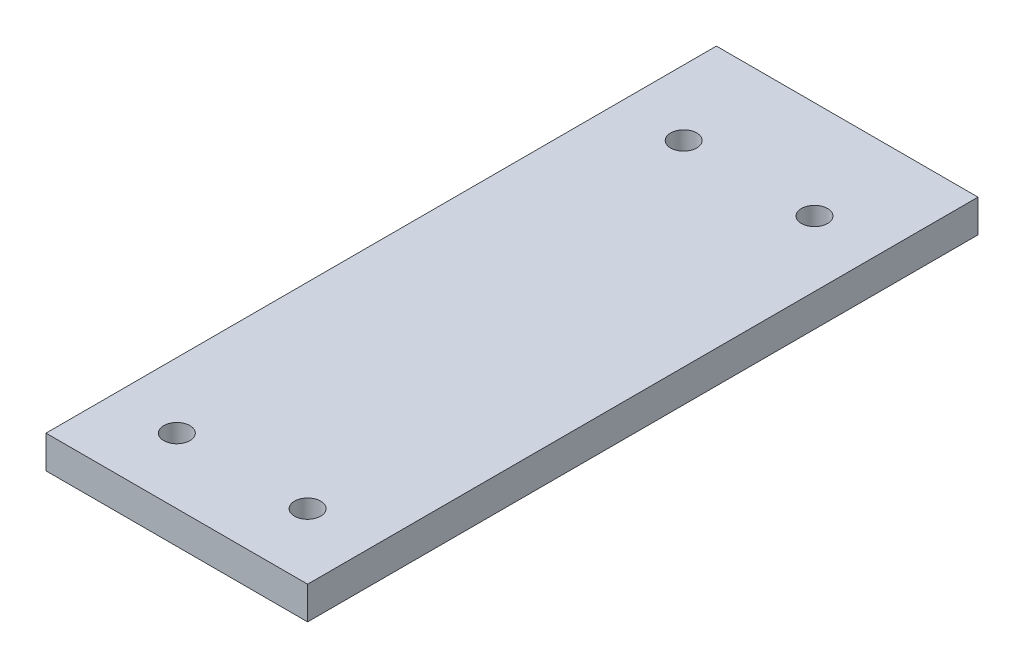
from build123d import *

# Parameters (mm, degrees)
SKETCH1_W           = 80
SKETCH1_H           = 205
BOSS_EXTRUDE1_DEPTH = 10
SKETCH2_R           = 4
CUT_EXTRUDE1_DEPTH  = 10
SKETCH3_R           = 4
CUT_EXTRUDE2_DEPTH  = 10
SKETCH4_W           = 0.314102564
SKETCH4_H           = 2.557692308
BOSS_EXTRUDE3_DEPTH = 1


with BuildPart() as part:
    # Sketch1 → Boss-Extrude1 (new body)
    with BuildSketch(Plane(origin=(0, 0, 0), x_dir=(1, 0, 0), z_dir=(0, 1, 0))):
        with Locations((-9.430434826, 48.783783784)):
            Rectangle(SKETCH1_W, SKETCH1_H)
    extrude(amount=BOSS_EXTRUDE1_DEPTH)

    # Sketch2 → Cut-Extrude1 (cut)
    with BuildSketch(Plane(origin=(0, 0, 0), x_dir=(-1, 0, 0), z_dir=(0, -1, 0))):
        with Locations((29.430434826, -33.716216216)):
            Circle(SKETCH2_R)
        with Locations((-10.569565174, -33.716216216)):
            Circle(SKETCH2_R)
    extrude(amount=-CUT_EXTRUDE1_DEPTH, mode=Mode.SUBTRACT)

    # Sketch3 → Cut-Extrude2 (cut)
    with BuildSketch(Plane(origin=(0, 0, 0), x_dir=(-1, 0, 0), z_dir=(0, -1, 0))):
        with Locations((29.430434826, 121.283783784)):
            Circle(SKETCH3_R)
        with Locations((-10.569565174, 121.283783784)):
            Circle(SKETCH3_R)
    extrude(amount=-CUT_EXTRUDE2_DEPTH, mode=Mode.SUBTRACT)

    # Sketch4 → Boss-Extrude3 (add)
    with BuildSketch(Plane.XZ):
        Polygon((-22.233507824, -126.696268606), (-21.771468561, -123.196268606), (-21.726596766, -123.196268606), (-20.281584747, -126.068063478), (-18.840078336, -123.196268606), (-18.79450542, -123.196268606), (-18.32966167, -126.696268606), (-18.645166477, -126.696268606), (-18.980302695, -124.177839119), (-20.24372417, -126.696268606), (-20.314537471, -126.696268606), (-21.582866798, -124.172230144), (-21.917301894, -126.696268606), align=None)
        with BuildLine():
            add(Edge.make_bspline(
                [(-16.466079939, -124.093704503), (-16.418088666, -124.094726394), (-16.323989508, -124.096730073), (-16.186181623, -124.118145039), (-16.054636487, -124.150892403), (-15.928850295, -124.196163965), (-15.810433999, -124.256845916), (-15.697662755, -124.329255207), (-15.590845746, -124.415037801), (-15.526822717, -124.481395869), (-15.494325131, -124.515078702)],
                knots=[0, 0, 0, 0, 0.000143868, 0.000282091, 0.000417278, 0.000550139, 0.000682145, 0.000815559, 0.000951665, 0.001091969, 0.001091969, 0.001091969, 0.001091969], degree=3))
            add(Edge.make_bspline(
                [(-15.494325131, -124.515078702), (-15.466343177, -124.547292688), (-15.410920797, -124.61109723), (-15.339855078, -124.714552843), (-15.278633518, -124.821692944), (-15.229570557, -124.93394027), (-15.190885533, -125.050314941), (-15.163419837, -125.171216953), (-15.147082902, -125.2963793), (-15.144879935, -125.381383138), (-15.143764234, -125.42443367)],
                knots=[0, 0, 0, 0, 0.000127922, 0.000253368, 0.000375813, 0.000497617, 0.000620225, 0.000743195, 0.000869033, 0.000998161, 0.000998161, 0.000998161, 0.000998161], degree=3))
            add(Edge.make_bspline(
                [(-15.143764234, -125.42443367), (-15.144745571, -125.467733728), (-15.146684739, -125.553296661), (-15.165028356, -125.679316027), (-15.193559442, -125.801510849), (-15.23439128, -125.919369543), (-15.286749389, -126.033252371), (-15.350640077, -126.14266192), (-15.426511694, -126.247814053), (-15.512515691, -126.347815891), (-15.607567567, -126.439982106), (-15.710683715, -126.520310376), (-15.819837749, -126.5891319), (-15.936481102, -126.644568316), (-16.059548589, -126.688278016), (-16.189305657, -126.718978033), (-16.325550727, -126.737539716), (-16.418577949, -126.73992329), (-16.466079939, -126.741140401)],
                knots=[0, 0, 0, 0, 0.000129829, 0.000256548, 0.000381202, 0.000505812, 0.000630045, 0.000756669, 0.000885282, 0.001018518, 0.001151902, 0.001281775, 0.001409974, 0.001538236, 0.001668405, 0.001801048, 0.001937587, 0.002080055, 0.002080055, 0.002080055, 0.002080055], degree=3))
            add(Edge.make_bspline(
                [(-16.466079939, -126.741140401), (-16.513814658, -126.739919205), (-16.607305518, -126.73752743), (-16.7440315, -126.719050147), (-16.874021119, -126.688292165), (-16.997249718, -126.644424672), (-17.114394564, -126.589130128), (-17.224181061, -126.520518439), (-17.327380977, -126.439958283), (-17.422452961, -126.347822346), (-17.508451567, -126.24781239), (-17.584324575, -126.142662352), (-17.648214901, -126.033252258), (-17.700573105, -125.919369573), (-17.741404918, -125.801510841), (-17.769936011, -125.679316029), (-17.788279625, -125.55329666), (-17.790218794, -125.467733727), (-17.791200131, -125.42443367)],
                knots=[0, 0, 0, 0, 0.000143168, 0.000280402, 0.000413045, 0.000543214, 0.000672108, 0.000800903, 0.000930775, 0.00106416, 0.001197395, 0.001326009, 0.001452632, 0.001576866, 0.001701476, 0.00182613, 0.001952849, 0.002082678, 0.002082678, 0.002082678, 0.002082678], degree=3))
            add(Edge.make_bspline(
                [(-17.791200131, -125.42443367), (-17.790076821, -125.381617124), (-17.787852859, -125.296847722), (-17.77153235, -125.171920661), (-17.744173794, -125.051223272), (-17.705442397, -124.935297796), (-17.655927206, -124.82354236), (-17.595565919, -124.716137529), (-17.523775286, -124.613149728), (-17.468573334, -124.549427648), (-17.440639234, -124.517182067)],
                knots=[0, 0, 0, 0, 0.000128428, 0.000254265, 0.000377235, 0.000499178, 0.000620341, 0.000743397, 0.000868267, 0.000996189, 0.000996189, 0.000996189, 0.000996189], degree=3))
            add(Edge.make_bspline(
                [(-17.440639234, -124.517182067), (-17.408190643, -124.483207128), (-17.344374779, -124.416389432), (-17.237026051, -124.330856908), (-17.12453223, -124.256940834), (-17.004807304, -124.197464619), (-16.879124446, -124.150626101), (-16.746905203, -124.118060586), (-16.608629688, -124.096807231), (-16.514070067, -124.094749053), (-16.466079939, -124.093704503)],
                knots=[0, 0, 0, 0, 0.000140798, 0.000276904, 0.000410699, 0.000543958, 0.000677061, 0.000812248, 0.000951858, 0.001095726, 0.001095726, 0.001095726, 0.001095726], degree=3))
        make_face()
        with BuildLine():
            add(Edge.make_bspline(
                [(-16.467482182, -124.407807067), (-16.501419794, -124.408771659), (-16.568418922, -124.410675942), (-16.667038507, -124.425159846), (-16.761978661, -124.44810735), (-16.853419505, -124.480711407), (-16.941052678, -124.522810306), (-17.02496208, -124.574518666), (-17.10539452, -124.635151622), (-17.180776583, -124.704614294), (-17.249958895, -124.780493288), (-17.310436872, -124.861341647), (-17.361861978, -124.945847994), (-17.404702137, -125.034100205), (-17.436609326, -125.126992619), (-17.459782348, -125.22347325), (-17.474252588, -125.323738666), (-17.476138967, -125.391899685), (-17.477097567, -125.426537035)],
                knots=[0, 0, 0, 0, 0.000101781, 0.000200935, 0.000298373, 0.000394396, 0.000491609, 0.000589491, 0.000689611, 0.000793323, 0.000896562, 0.000997243, 0.001095722, 0.001192936, 0.001290943, 0.001389744, 0.001490285, 0.001594167, 0.001594167, 0.001594167, 0.001594167], degree=3))
            add(Edge.make_bspline(
                [(-17.477097567, -125.426537035), (-17.475490743, -125.471289063), (-17.472301499, -125.560113468), (-17.446366263, -125.690924591), (-17.402979983, -125.816506443), (-17.344392703, -125.936122829), (-17.270986484, -126.046795107), (-17.184499418, -126.145466591), (-17.085859717, -126.230652403), (-16.976243217, -126.301333248), (-16.857888899, -126.357493004), (-16.732632578, -126.39729198), (-16.601991884, -126.423163672), (-16.512711153, -126.425735146), (-16.467482182, -126.427037837)],
                knots=[0, 0, 0, 0, 0.000134178, 0.000266319, 0.000398243, 0.00053182, 0.000664828, 0.000795487, 0.000924236, 0.001054533, 0.001185628, 0.001316003, 0.001448011, 0.001583547, 0.001583547, 0.001583547, 0.001583547], degree=3))
            add(Edge.make_bspline(
                [(-16.467482182, -126.427037837), (-16.422255814, -126.425727556), (-16.332980218, -126.4231411), (-16.202521041, -126.39742228), (-16.077607069, -126.357318619), (-15.959375681, -126.301396409), (-15.849809078, -126.230383994), (-15.750459957, -126.145947617), (-15.664711345, -126.046533766), (-15.591377741, -125.935976237), (-15.531830998, -125.816691885), (-15.488647796, -125.690901413), (-15.46265021, -125.560119371), (-15.459469381, -125.47129104), (-15.457866798, -125.426537035)],
                knots=[0, 0, 0, 0, 0.000135536, 0.000267545, 0.000397252, 0.000528347, 0.000658644, 0.000787925, 0.000918122, 0.00105113, 0.001185017, 0.001316942, 0.001449082, 0.00158326, 0.00158326, 0.00158326, 0.00158326], degree=3))
            add(Edge.make_bspline(
                [(-15.457866798, -125.426537035), (-15.458825068, -125.391899478), (-15.460710797, -125.323738052), (-15.475185761, -125.223475598), (-15.498341301, -125.126984002), (-15.530312918, -125.034131998), (-15.572966932, -124.945619494), (-15.625383725, -124.861589767), (-15.685614751, -124.780213221), (-15.755631872, -124.70485958), (-15.830935249, -124.635124544), (-15.911400288, -124.574495154), (-15.995185266, -124.523037559), (-16.082563849, -124.480351318), (-16.174016416, -124.448403978), (-16.268823546, -124.425027346), (-16.367022356, -124.41073715), (-16.433781399, -124.408790008), (-16.467482182, -124.407807067)],
                knots=[0, 0, 0, 0, 0.000103882, 0.000204424, 0.000303225, 0.000401232, 0.000498445, 0.000597291, 0.000697972, 0.000801684, 0.000905395, 0.001005516, 0.001103397, 0.001199979, 0.001296663, 0.00139342, 0.001492573, 0.001593654, 0.001593654, 0.001593654, 0.001593654], degree=3))
        make_face(mode=Mode.SUBTRACT)
        Polygon((-14.201456541, -123.106525016), (-13.887353977, -123.106525016), (-13.887353977, -124.138576298), (-13.438636029, -124.138576298), (-13.438636029, -124.452678862), (-13.887353977, -124.452678862), (-13.887353977, -126.696268606), (-14.201456541, -126.696268606), (-14.201456541, -124.452678862), (-14.65017449, -124.452678862), (-14.65017449, -124.138576298), (-14.201456541, -124.138576298), align=None)
        with BuildLine():
            add(Edge.make_bspline(
                [(-11.664797888, -124.093704503), (-11.616806615, -124.094726394), (-11.522707457, -124.096730073), (-11.384899571, -124.118145039), (-11.253354435, -124.150892403), (-11.127568243, -124.196163965), (-11.009151948, -124.256845916), (-10.896380704, -124.329255207), (-10.789563695, -124.415037801), (-10.725540666, -124.481395869), (-10.69304308, -124.515078702)],
                knots=[0, 0, 0, 0, 0.000143868, 0.000282091, 0.000417278, 0.000550139, 0.000682145, 0.000815559, 0.000951665, 0.001091969, 0.001091969, 0.001091969, 0.001091969], degree=3))
            add(Edge.make_bspline(
                [(-10.69304308, -124.515078702), (-10.665061126, -124.547292688), (-10.609638746, -124.61109723), (-10.538573027, -124.714552843), (-10.477351467, -124.821692944), (-10.428288506, -124.93394027), (-10.389603482, -125.050314941), (-10.362137786, -125.171216953), (-10.345800851, -125.2963793), (-10.343597884, -125.381383138), (-10.342482182, -125.42443367)],
                knots=[0, 0, 0, 0, 0.000127922, 0.000253368, 0.000375813, 0.000497617, 0.000620225, 0.000743195, 0.000869033, 0.000998161, 0.000998161, 0.000998161, 0.000998161], degree=3))
            add(Edge.make_bspline(
                [(-10.342482182, -125.42443367), (-10.34346352, -125.467733728), (-10.345402688, -125.553296661), (-10.363746305, -125.679316027), (-10.39227739, -125.801510849), (-10.433109229, -125.919369543), (-10.485467338, -126.033252371), (-10.549358025, -126.14266192), (-10.625229643, -126.247814053), (-10.711233639, -126.347815891), (-10.806285515, -126.439982106), (-10.909401664, -126.520310376), (-11.018555697, -126.5891319), (-11.135199051, -126.644568316), (-11.258266538, -126.688278016), (-11.388023606, -126.718978033), (-11.524268676, -126.737539716), (-11.617295897, -126.73992329), (-11.664797888, -126.741140401)],
                knots=[0, 0, 0, 0, 0.000129829, 0.000256548, 0.000381202, 0.000505812, 0.000630045, 0.000756669, 0.000885282, 0.001018518, 0.001151902, 0.001281775, 0.001409974, 0.001538236, 0.001668405, 0.001801048, 0.001937587, 0.002080055, 0.002080055, 0.002080055, 0.002080055], degree=3))
            add(Edge.make_bspline(
                [(-11.664797888, -126.741140401), (-11.712532607, -126.739919205), (-11.806023467, -126.73752743), (-11.942749449, -126.719050147), (-12.072739068, -126.688292165), (-12.195967666, -126.644424672), (-12.313112513, -126.589130128), (-12.42289901, -126.520518439), (-12.526098926, -126.439958283), (-12.62117091, -126.347822346), (-12.707169515, -126.24781239), (-12.783042524, -126.142662352), (-12.84693285, -126.033252258), (-12.899291054, -125.919369573), (-12.940122867, -125.801510841), (-12.968653959, -125.679316029), (-12.986997574, -125.55329666), (-12.988936742, -125.467733727), (-12.98991808, -125.42443367)],
                knots=[0, 0, 0, 0, 0.000143168, 0.000280402, 0.000413045, 0.000543214, 0.000672108, 0.000800903, 0.000930775, 0.00106416, 0.001197395, 0.001326009, 0.001452632, 0.001576866, 0.001701476, 0.00182613, 0.001952849, 0.002082678, 0.002082678, 0.002082678, 0.002082678], degree=3))
            add(Edge.make_bspline(
                [(-12.98991808, -125.42443367), (-12.98879477, -125.381617124), (-12.986570808, -125.296847722), (-12.970250299, -125.171920661), (-12.942891743, -125.051223272), (-12.904160346, -124.935297796), (-12.854645155, -124.82354236), (-12.794283867, -124.716137529), (-12.722493235, -124.613149728), (-12.667291283, -124.549427648), (-12.639357182, -124.517182067)],
                knots=[0, 0, 0, 0, 0.000128428, 0.000254265, 0.000377235, 0.000499178, 0.000620341, 0.000743397, 0.000868267, 0.000996189, 0.000996189, 0.000996189, 0.000996189], degree=3))
            add(Edge.make_bspline(
                [(-12.639357182, -124.517182067), (-12.606908591, -124.483207128), (-12.543092728, -124.416389432), (-12.435744, -124.330856908), (-12.323250179, -124.256940834), (-12.203525253, -124.197464619), (-12.077842395, -124.150626101), (-11.945623152, -124.118060586), (-11.807347637, -124.096807231), (-11.712788016, -124.094749053), (-11.664797888, -124.093704503)],
                knots=[0, 0, 0, 0, 0.000140798, 0.000276904, 0.000410699, 0.000543958, 0.000677061, 0.000812248, 0.000951858, 0.001095726, 0.001095726, 0.001095726, 0.001095726], degree=3))
        make_face()
        with BuildLine():
            add(Edge.make_bspline(
                [(-11.666200131, -124.407807067), (-11.700137743, -124.408771659), (-11.767136871, -124.410675942), (-11.865756456, -124.425159846), (-11.96069661, -124.44810735), (-12.052137454, -124.480711407), (-12.139770626, -124.522810306), (-12.223680029, -124.574518666), (-12.304112469, -124.635151622), (-12.379494532, -124.704614294), (-12.448676844, -124.780493288), (-12.509154821, -124.861341647), (-12.560579927, -124.945847994), (-12.603420086, -125.034100205), (-12.635327274, -125.126992619), (-12.658500297, -125.22347325), (-12.672970537, -125.323738666), (-12.674856916, -125.391899685), (-12.675815516, -125.426537035)],
                knots=[0, 0, 0, 0, 0.000101781, 0.000200935, 0.000298373, 0.000394396, 0.000491609, 0.000589491, 0.000689611, 0.000793323, 0.000896562, 0.000997243, 0.001095722, 0.001192936, 0.001290943, 0.001389744, 0.001490285, 0.001594167, 0.001594167, 0.001594167, 0.001594167], degree=3))
            add(Edge.make_bspline(
                [(-12.675815516, -125.426537035), (-12.674208692, -125.471289063), (-12.671019448, -125.560113468), (-12.645084211, -125.690924591), (-12.601697931, -125.816506443), (-12.543110652, -125.936122829), (-12.469704433, -126.046795107), (-12.383217366, -126.145466591), (-12.284577666, -126.230652403), (-12.174961166, -126.301333248), (-12.056606848, -126.357493004), (-11.931350527, -126.39729198), (-11.800709833, -126.423163672), (-11.711429102, -126.425735146), (-11.666200131, -126.427037837)],
                knots=[0, 0, 0, 0, 0.000134178, 0.000266319, 0.000398243, 0.00053182, 0.000664828, 0.000795487, 0.000924236, 0.001054533, 0.001185628, 0.001316003, 0.001448011, 0.001583547, 0.001583547, 0.001583547, 0.001583547], degree=3))
            add(Edge.make_bspline(
                [(-11.666200131, -126.427037837), (-11.620973762, -126.425727556), (-11.531698166, -126.4231411), (-11.401238989, -126.39742228), (-11.276325018, -126.357318619), (-11.15809363, -126.301396409), (-11.048527027, -126.230383994), (-10.949177905, -126.145947617), (-10.863429294, -126.046533766), (-10.790095689, -125.935976237), (-10.730548947, -125.816691885), (-10.687365745, -125.690901413), (-10.661368159, -125.560119371), (-10.65818733, -125.47129104), (-10.656584747, -125.426537035)],
                knots=[0, 0, 0, 0, 0.000135536, 0.000267545, 0.000397252, 0.000528347, 0.000658644, 0.000787925, 0.000918122, 0.00105113, 0.001185017, 0.001316942, 0.001449082, 0.00158326, 0.00158326, 0.00158326, 0.00158326], degree=3))
            add(Edge.make_bspline(
                [(-10.656584747, -125.426537035), (-10.657543017, -125.391899478), (-10.659428746, -125.323738052), (-10.67390371, -125.223475598), (-10.69705925, -125.126984002), (-10.729030867, -125.034131998), (-10.771684881, -124.945619494), (-10.824101674, -124.861589767), (-10.884332699, -124.780213221), (-10.95434982, -124.70485958), (-11.029653198, -124.635124544), (-11.110118236, -124.574495154), (-11.193903215, -124.523037559), (-11.281281798, -124.480351318), (-11.372734365, -124.448403978), (-11.467541494, -124.425027346), (-11.565740304, -124.41073715), (-11.632499347, -124.408790008), (-11.666200131, -124.407807067)],
                knots=[0, 0, 0, 0, 0.000103882, 0.000204424, 0.000303225, 0.000401232, 0.000498445, 0.000597291, 0.000697972, 0.000801684, 0.000905395, 0.001005516, 0.001103397, 0.001199979, 0.001296663, 0.00139342, 0.001492573, 0.001593654, 0.001593654, 0.001593654, 0.001593654], degree=3))
        make_face(mode=Mode.SUBTRACT)
        with BuildLine():
            Line((-9.804020644, -124.138576298), (-9.48991808, -124.138576298))
            Line((-9.48991808, -124.138576298), (-9.48991808, -124.515078702))
            add(Edge.make_bspline(
                [(-9.48991808, -124.515078702), (-9.466729321, -124.480022874), (-9.422381, -124.412978874), (-9.348668071, -124.324309573), (-9.27316474, -124.250894527), (-9.195509552, -124.192391008), (-9.115131452, -124.148577889), (-9.033794501, -124.116484854), (-8.950219031, -124.097507539), (-8.894057107, -124.09497388), (-8.865919682, -124.093704503)],
                knots=[0, 0, 0, 0, 0.000126023, 0.000241017, 0.000345147, 0.000441342, 0.00053171, 0.000618946, 0.000702978, 0.000787349, 0.000787349, 0.000787349, 0.000787349], degree=3))
            add(Edge.make_bspline(
                [(-8.865919682, -124.093704503), (-8.844093356, -124.09489503), (-8.799184271, -124.097344616), (-8.731201681, -124.11455544), (-8.661158229, -124.142033463), (-8.616015842, -124.167873686), (-8.592482182, -124.181344728)],
                knots=[0, 0, 0, 0, 6.5445e-05, 0.000134658, 0.00020926, 0.000290509, 0.000290509, 0.000290509, 0.000290509], degree=3))
            Line((-8.592482182, -124.181344728), (-8.764958144, -124.453379984))
            add(Edge.make_bspline(
                [(-8.764958144, -124.453379984), (-8.780067165, -124.446639718), (-8.80874698, -124.433845403), (-8.850701546, -124.418703392), (-8.889382883, -124.409787477), (-8.914026441, -124.408436759), (-8.925515035, -124.407807067)],
                knots=[0, 0, 0, 0, 4.9621e-05, 9.4191e-05, 0.00013366, 0.000168129, 0.000168129, 0.000168129, 0.000168129], degree=3))
            add(Edge.make_bspline(
                [(-8.925515035, -124.407807067), (-8.950720769, -124.409487105), (-9.002133159, -124.412913894), (-9.077617658, -124.439852702), (-9.150864863, -124.483377942), (-9.209036526, -124.531649054), (-9.254078779, -124.578196851), (-9.286219004, -124.618845254), (-9.315701751, -124.664423885), (-9.343871972, -124.714153569), (-9.369538266, -124.768883415), (-9.393492935, -124.828066629), (-9.415151798, -124.891771757), (-9.427502042, -124.936154278), (-9.433828336, -124.958888798)],
                knots=[0, 0, 0, 0, 7.549e-05, 0.000153978, 0.000237553, 0.000330197, 0.000379784, 0.000431685, 0.000485357, 0.000542493, 0.000603021, 0.000666557, 0.00073396, 0.000804745, 0.000804745, 0.000804745, 0.000804745], degree=3))
            add(Edge.make_bspline(
                [(-9.433828336, -124.958888798), (-9.43856073, -124.979165972), (-9.449042621, -125.02407837), (-9.459234159, -125.099426895), (-9.469303677, -125.188450554), (-9.476400296, -125.291397147), (-9.482978338, -125.408009591), (-9.48668842, -125.538465536), (-9.48979156, -125.682898887), (-9.489874627, -125.783873241), (-9.48991808, -125.836693285)],
                knots=[0, 0, 0, 0, 6.2435e-05, 0.000138289, 0.000227871, 0.000331224, 0.000447781, 0.000578258, 0.000722716, 0.000881171, 0.000881171, 0.000881171, 0.000881171], degree=3))
            Line((-9.48991808, -125.836693285), (-9.48991808, -126.696268606))
            Line((-9.48991808, -126.696268606), (-9.804020644, -126.696268606))
            Line((-9.804020644, -126.696268606), (-9.804020644, -124.138576298))
        make_face()
        with BuildLine():
            Line((-5.720687311, -124.457586715), (-5.933828336, -124.677037837))
            add(Edge.make_bspline(
                [(-5.933828336, -124.677037837), (-5.95221884, -124.65572469), (-5.987673566, -124.614635453), (-6.043905047, -124.559698387), (-6.09992865, -124.513561448), (-6.154977464, -124.474609189), (-6.210435733, -124.445160042), (-6.265652651, -124.42366518), (-6.32068539, -124.410363375), (-6.357471425, -124.408648936), (-6.375535067, -124.407807067)],
                knots=[0, 0, 0, 0, 8.4426e-05, 0.000162764, 0.000235478, 0.000301992, 0.000364722, 0.000423315, 0.00047944, 0.00053359, 0.00053359, 0.00053359, 0.00053359], degree=3))
            add(Edge.make_bspline(
                [(-6.375535067, -124.407807067), (-6.397674457, -124.40888194), (-6.441241643, -124.410997138), (-6.503667461, -124.432110569), (-6.561618086, -124.464519307), (-6.611775066, -124.510487891), (-6.654262746, -124.563252159), (-6.685276427, -124.622248484), (-6.704242411, -124.685696528), (-6.706647143, -124.729726386), (-6.707866798, -124.752057869)],
                knots=[0, 0, 0, 0, 6.6207e-05, 0.000130286, 0.000195595, 0.000264126, 0.000333001, 0.000397918, 0.000462926, 0.000529831, 0.000529831, 0.000529831, 0.000529831], degree=3))
            add(Edge.make_bspline(
                [(-6.707866798, -124.752057869), (-6.706755986, -124.772269913), (-6.704537492, -124.812637024), (-6.687290813, -124.872185058), (-6.659824741, -124.930242096), (-6.634154547, -124.965805002), (-6.620927695, -124.984129183)],
                knots=[0, 0, 0, 0, 6.0557e-05, 0.000120943, 0.000184606, 0.000252278, 0.000252278, 0.000252278, 0.000252278], degree=3))
            add(Edge.make_bspline(
                [(-6.620927695, -124.984129183), (-6.612964202, -124.993913767), (-6.596014909, -125.014739022), (-6.564206394, -125.043642875), (-6.528183891, -125.075585126), (-6.484863953, -125.107521963), (-6.436112925, -125.141153688), (-6.380873641, -125.175155821), (-6.320899136, -125.212120246), (-6.277961829, -125.235564682), (-6.25564324, -125.247750978)],
                knots=[0, 0, 0, 0, 3.7796e-05, 8.0443e-05, 0.000128658, 0.000182224, 0.000241732, 0.000306315, 0.000376777, 0.000453048, 0.000453048, 0.000453048, 0.000453048], degree=3))
            add(Edge.make_bspline(
                [(-6.25564324, -125.247750978), (-6.228429663, -125.26299588), (-6.175861993, -125.292444013), (-6.101169226, -125.338153716), (-6.033382185, -125.383585141), (-5.971926517, -125.428252415), (-5.917984708, -125.473405282), (-5.869920156, -125.517313039), (-5.828931712, -125.561302347), (-5.805977785, -125.592035461), (-5.795006221, -125.606725337)],
                knots=[0, 0, 0, 0, 9.3573e-05, 0.000180752, 0.000262618, 0.000338343, 0.000408542, 0.000473535, 0.000533574, 0.000588549, 0.000588549, 0.000588549, 0.000588549], degree=3))
            add(Edge.make_bspline(
                [(-5.795006221, -125.606725337), (-5.776795694, -125.636391425), (-5.740553364, -125.695432446), (-5.702495098, -125.792650873), (-5.680434823, -125.895761376), (-5.677372603, -125.966293596), (-5.675815516, -126.002158029)],
                knots=[0, 0, 0, 0, 0.000104269, 0.000207515, 0.000311475, 0.000419024, 0.000419024, 0.000419024, 0.000419024], degree=3))
            add(Edge.make_bspline(
                [(-5.675815516, -126.002158029), (-5.67653505, -126.027427175), (-5.67795297, -126.077222788), (-5.687811037, -126.150557618), (-5.704766013, -126.220692176), (-5.727859767, -126.28838746), (-5.75904414, -126.3523464), (-5.795591937, -126.414182649), (-5.839466849, -126.47255858), (-5.889558224, -126.52739754), (-5.944403718, -126.577483287), (-6.002909857, -126.621507241), (-6.065148687, -126.658081578), (-6.130675489, -126.688346924), (-6.199639143, -126.712415181), (-6.272050432, -126.729077713), (-6.347679187, -126.739050474), (-6.399108995, -126.74043495), (-6.425314715, -126.741140401)],
                knots=[0, 0, 0, 0, 7.5802e-05, 0.000149377, 0.00022148, 0.00029199, 0.000363491, 0.000434554, 0.00050719, 0.000582132, 0.000657073, 0.000729709, 0.000801375, 0.000873212, 0.000945939, 0.001020089, 0.001095749, 0.001174353, 0.001174353, 0.001174353, 0.001174353], degree=3))
            add(Edge.make_bspline(
                [(-6.425314715, -126.741140401), (-6.46068189, -126.7401477), (-6.530924817, -126.738176093), (-6.634814536, -126.719670032), (-6.736335295, -126.690874638), (-6.834718835, -126.651158704), (-6.927764949, -126.601007991), (-7.012895874, -126.540945598), (-7.090407336, -126.4729556), (-7.13452561, -126.420842689), (-7.156584747, -126.394786234)],
                knots=[0, 0, 0, 0, 0.000106018, 0.000210563, 0.000315537, 0.000422167, 0.000528204, 0.00063188, 0.000734181, 0.000836482, 0.000836482, 0.000836482, 0.000836482], degree=3))
            Line((-7.156584747, -126.394786234), (-6.948351574, -126.157807067))
            add(Edge.make_bspline(
                [(-6.948351574, -126.157807067), (-6.928579161, -126.179161832), (-6.890247348, -126.220561272), (-6.828946132, -126.275685613), (-6.76656673, -126.321886884), (-6.703732044, -126.360530298), (-6.63951195, -126.390305702), (-6.574266335, -126.411224296), (-6.508127911, -126.424668488), (-6.463705775, -126.42624677), (-6.441440516, -126.427037837)],
                knots=[0, 0, 0, 0, 8.7278e-05, 0.000169201, 0.000246886, 0.000319874, 0.000390144, 0.000458657, 0.000525071, 0.00059181, 0.00059181, 0.00059181, 0.00059181], degree=3))
            add(Edge.make_bspline(
                [(-6.441440516, -126.427037837), (-6.41112259, -126.425667012), (-6.351886448, -126.42298865), (-6.26704269, -126.398671558), (-6.188704063, -126.360541606), (-6.120680718, -126.306456908), (-6.062778557, -126.243501335), (-6.020850382, -126.172587216), (-5.994574207, -126.095795759), (-5.991488208, -126.042563457), (-5.98991808, -126.015479343)],
                knots=[0, 0, 0, 0, 9.0773e-05, 0.000177355, 0.000262642, 0.000350576, 0.00043646, 0.000517865, 0.000596131, 0.000677197, 0.000677197, 0.000677197, 0.000677197], degree=3))
            add(Edge.make_bspline(
                [(-5.98991808, -126.015479343), (-5.991004374, -125.993169724), (-5.993149117, -125.949122369), (-6.009992389, -125.885372028), (-6.036605241, -125.824902747), (-6.06280989, -125.7895131), (-6.076156061, -125.771488958)],
                knots=[0, 0, 0, 0, 6.6842e-05, 0.000131971, 0.000196611, 0.000263703, 0.000263703, 0.000263703, 0.000263703], degree=3))
            add(Edge.make_bspline(
                [(-6.076156061, -125.771488958), (-6.084178455, -125.762453596), (-6.101654128, -125.742771314), (-6.133709369, -125.714346235), (-6.172091231, -125.683708136), (-6.217231394, -125.651376547), (-6.269220856, -125.617777942), (-6.328270331, -125.58308859), (-6.393570884, -125.545660864), (-6.439741515, -125.520841209), (-6.463876413, -125.507867164)],
                knots=[0, 0, 0, 0, 3.6222e-05, 7.8904e-05, 0.000128287, 0.000183547, 0.000245389, 0.000313927, 0.000388976, 0.000471175, 0.000471175, 0.000471175, 0.000471175], degree=3))
            add(Edge.make_bspline(
                [(-6.463876413, -125.507867164), (-6.489923053, -125.493328032), (-6.540435801, -125.465132016), (-6.611983092, -125.421215935), (-6.676530446, -125.376548661), (-6.735631021, -125.333635821), (-6.787792026, -125.290214877), (-6.832807974, -125.246237626), (-6.87245119, -125.20347764), (-6.894398602, -125.173180343), (-6.904882022, -125.15870851)],
                knots=[0, 0, 0, 0, 8.9486e-05, 0.000173541, 0.000251719, 0.000324918, 0.000392605, 0.000455079, 0.000513655, 0.000567221, 0.000567221, 0.000567221, 0.000567221], degree=3))
            add(Edge.make_bspline(
                [(-6.904882022, -125.15870851), (-6.923012622, -125.129562895), (-6.959280157, -125.071261479), (-6.994495348, -124.973951003), (-7.018701377, -124.871505945), (-7.020863767, -124.800819091), (-7.021969362, -124.764678061)],
                knots=[0, 0, 0, 0, 0.000102704, 0.000205444, 0.000308869, 0.000417069, 0.000417069, 0.000417069, 0.000417069], degree=3))
            add(Edge.make_bspline(
                [(-7.021969362, -124.764678061), (-7.021435167, -124.741052663), (-7.020389671, -124.694814412), (-7.012045619, -124.626875592), (-6.996853908, -124.562327438), (-6.977798985, -124.500200575), (-6.951315981, -124.441698481), (-6.919670076, -124.38604101), (-6.882482651, -124.333305092), (-6.83963936, -124.28430196), (-6.792532715, -124.239792633), (-6.741637945, -124.200994005), (-6.688099688, -124.167887651), (-6.631691269, -124.14012249), (-6.571870796, -124.119121107), (-6.50905641, -124.104663722), (-6.443375255, -124.09500852), (-6.398474129, -124.094145435), (-6.375535067, -124.093704503)],
                knots=[0, 0, 0, 0, 7.0869e-05, 0.0001387, 0.000204863, 0.000269609, 0.000333323, 0.000397067, 0.000461456, 0.000526554, 0.000592026, 0.00065555, 0.000718201, 0.000780601, 0.000843799, 0.000907913, 0.000973751, 0.001042518, 0.001042518, 0.001042518, 0.001042518], degree=3))
            add(Edge.make_bspline(
                [(-6.375535067, -124.093704503), (-6.348343004, -124.094808844), (-6.293448782, -124.097038242), (-6.211094156, -124.114743932), (-6.128860814, -124.143877036), (-6.046537464, -124.18411327), (-5.964727174, -124.236180146), (-5.882710318, -124.299109445), (-5.799502287, -124.372487159), (-5.747545974, -124.428586385), (-5.720687311, -124.457586715)],
                knots=[0, 0, 0, 0, 8.1523e-05, 0.000164576, 0.000251498, 0.000342746, 0.000438841, 0.000541908, 0.000652652, 0.000771167, 0.000771167, 0.000771167, 0.000771167], degree=3))
        make_face()
        with BuildLine():
            add(Edge.make_bspline(
                [(-4.936833144, -123.061653221), (-4.917341828, -123.062557374), (-4.879174088, -123.064327878), (-4.823980821, -123.079489355), (-4.773723809, -123.10518904), (-4.729146076, -123.139668721), (-4.690894189, -123.180218165), (-4.664113479, -123.227479133), (-4.646901083, -123.278537772), (-4.644822527, -123.314152861), (-4.643764234, -123.332286234)],
                knots=[0, 0, 0, 0, 5.84e-05, 0.000114358, 0.000170171, 0.000226684, 0.000282761, 0.000336156, 0.000388483, 0.00044276, 0.00044276, 0.00044276, 0.00044276], degree=3))
            add(Edge.make_bspline(
                [(-4.643764234, -123.332286234), (-4.644846394, -123.349948887), (-4.646985695, -123.384865862), (-4.664100184, -123.435039334), (-4.691122422, -123.481643618), (-4.729121547, -123.522114328), (-4.773730308, -123.556574948), (-4.823979094, -123.582279687), (-4.879174543, -123.597439824), (-4.917341982, -123.599210513), (-4.936833144, -123.60011476)],
                knots=[0, 0, 0, 0, 5.2882e-05, 0.000104542, 0.000157332, 0.000213408, 0.000269922, 0.000325735, 0.000381693, 0.000440092, 0.000440092, 0.000440092, 0.000440092], degree=3))
            add(Edge.make_bspline(
                [(-4.936833144, -123.60011476), (-4.956101419, -123.59924504), (-4.993604599, -123.597552243), (-5.047971442, -123.581982225), (-5.097799931, -123.556566152), (-5.142464604, -123.522339967), (-5.179694797, -123.48139507), (-5.206793122, -123.435067776), (-5.223868084, -123.384858621), (-5.226012713, -123.349946455), (-5.227097567, -123.332286234)],
                knots=[0, 0, 0, 0, 5.7701e-05, 0.000112308, 0.000168121, 0.000224634, 0.000280239, 0.000333029, 0.000384689, 0.000437571, 0.000437571, 0.000437571, 0.000437571], degree=3))
            add(Edge.make_bspline(
                [(-5.227097567, -123.332286234), (-5.22603648, -123.314155384), (-5.223952439, -123.278545252), (-5.206780323, -123.227450219), (-5.179920516, -123.180468717), (-5.142439952, -123.139443218), (-5.097806492, -123.105197783), (-5.047969747, -123.079786801), (-4.993605047, -123.064215462), (-4.956101571, -123.062522848), (-4.936833144, -123.061653221)],
                knots=[0, 0, 0, 0, 5.4277e-05, 0.000106603, 0.000159999, 0.000215605, 0.000272118, 0.000327931, 0.000382538, 0.000440239, 0.000440239, 0.000440239, 0.000440239], degree=3))
        make_face()
        with Locations((-4.9354309, -125.417422452)):
            Rectangle(SKETCH4_W, SKETCH4_H)
        with BuildLine():
            Line((-1.412995003, -123.106525016), (-1.412995003, -126.696268606))
            Line((-1.412995003, -126.696268606), (-1.727097567, -126.696268606))
            Line((-1.727097567, -126.696268606), (-1.727097567, -126.253860753))
            add(Edge.make_bspline(
                [(-1.727097567, -126.253860753), (-1.762516358, -126.293900347), (-1.831636573, -126.372038118), (-1.947077691, -126.474120291), (-2.069445869, -126.558498612), (-2.19814719, -126.626648528), (-2.333065433, -126.677840584), (-2.473901521, -126.714226744), (-2.620712902, -126.737620579), (-2.720965256, -126.739956601), (-2.771769041, -126.741140401)],
                knots=[0, 0, 0, 0, 0.000160263, 0.000312755, 0.000460949, 0.000605216, 0.000748578, 0.000892786, 0.001041028, 0.001193333, 0.001193333, 0.001193333, 0.001193333], degree=3))
            add(Edge.make_bspline(
                [(-2.771769041, -126.741140401), (-2.816936995, -126.739914028), (-2.9060102, -126.737495568), (-3.037039277, -126.718733264), (-3.163131527, -126.688602643), (-3.284406099, -126.646701753), (-3.400078245, -126.591120932), (-3.511138342, -126.524579684), (-3.617011034, -126.445338854), (-3.716082573, -126.354750825), (-3.807314573, -126.256355838), (-3.887375846, -126.151410291), (-3.954128925, -126.040367987), (-4.009949006, -125.924634833), (-4.052945351, -125.803319914), (-4.082918985, -125.676842746), (-4.101659431, -125.545352872), (-4.104076892, -125.455813349), (-4.105302695, -125.410411234)],
                knots=[0, 0, 0, 0, 0.000135464, 0.00026714, 0.000396211, 0.000523931, 0.000651257, 0.000780517, 0.000911767, 0.001047265, 0.00118272, 0.001313831, 0.001442491, 0.001570752, 0.001698704, 0.001827775, 0.001960146, 0.00209631, 0.00209631, 0.00209631, 0.00209631], degree=3))
            add(Edge.make_bspline(
                [(-4.105302695, -125.410411234), (-4.104049724, -125.365947531), (-4.101572667, -125.278045187), (-4.083119447, -125.148766489), (-4.052088439, -125.024248228), (-4.008540591, -124.904891285), (-3.952698636, -124.790551235), (-3.884770549, -124.68114721), (-3.804751424, -124.576377813), (-3.712499017, -124.478706586), (-3.612564247, -124.388485972), (-3.505655516, -124.310076926), (-3.394432235, -124.242360077), (-3.277169224, -124.188706601), (-3.155602119, -124.145297496), (-3.028648674, -124.115264528), (-2.896837095, -124.097567207), (-2.807346603, -124.095004443), (-2.761953336, -124.093704503)],
                knots=[0, 0, 0, 0, 0.000133363, 0.00026365, 0.000390846, 0.000517716, 0.000644083, 0.000771912, 0.000903449, 0.001038867, 0.001174416, 0.001306792, 0.001436052, 0.00156435, 0.001692963, 0.001822716, 0.001954992, 0.002091156, 0.002091156, 0.002091156, 0.002091156], degree=3))
            add(Edge.make_bspline(
                [(-2.761953336, -124.093704503), (-2.709736529, -124.095271599), (-2.607240738, -124.098347635), (-2.457342216, -124.124054002), (-2.315554606, -124.16721688), (-2.181061618, -124.226308161), (-2.054665058, -124.303108912), (-1.935438418, -124.39586036), (-1.825455095, -124.507187506), (-1.760383272, -124.59079908), (-1.727097567, -124.633568285)],
                knots=[0, 0, 0, 0, 0.000156576, 0.000307342, 0.000454614, 0.000600266, 0.00074684, 0.00089719, 0.001052366, 0.001214863, 0.001214863, 0.001214863, 0.001214863], degree=3))
            Line((-1.727097567, -124.633568285), (-1.727097567, -123.106525016))
            Line((-1.727097567, -123.106525016), (-1.412995003, -123.106525016))
        make_face()
        with BuildLine():
            add(Edge.make_bspline(
                [(-2.757746606, -124.407807067), (-2.803660943, -124.409440705), (-2.894288543, -124.412665246), (-3.027332545, -124.437838741), (-3.15464596, -124.479723336), (-3.275592034, -124.537005237), (-3.38826025, -124.609033974), (-3.488953921, -124.696155357), (-3.578496623, -124.795992371), (-3.653804887, -124.908094481), (-3.715195384, -125.028272572), (-3.758362416, -125.153897011), (-3.786831663, -125.282701988), (-3.789740184, -125.370064674), (-3.791200131, -125.413916843)],
                knots=[0, 0, 0, 0, 0.000137677, 0.000271753, 0.000404561, 0.000538791, 0.000672205, 0.000804452, 0.00093703, 0.001073348, 0.00120849, 0.001340643, 0.001470999, 0.001602378, 0.001602378, 0.001602378, 0.001602378], degree=3))
            add(Edge.make_bspline(
                [(-3.791200131, -125.413916843), (-3.789335238, -125.45750695), (-3.785612761, -125.544516306), (-3.758862067, -125.673496883), (-3.713982193, -125.799150925), (-3.65274013, -125.920411918), (-3.576053506, -126.032996019), (-3.487164853, -126.134736141), (-3.385214572, -126.22222573), (-3.272287065, -126.295463303), (-3.151679094, -126.354625824), (-3.024845163, -126.395791464), (-2.894169525, -126.422369244), (-2.805317191, -126.425473721), (-2.760551093, -126.427037837)],
                knots=[0, 0, 0, 0, 0.000130727, 0.000260941, 0.000393327, 0.000530037, 0.000667328, 0.000800955, 0.000934191, 0.001068956, 0.001203792, 0.001335934, 0.001468075, 0.001602253, 0.001602253, 0.001602253, 0.001602253], degree=3))
            add(Edge.make_bspline(
                [(-2.760551093, -126.427037837), (-2.71510459, -126.425377873), (-2.624716003, -126.422076369), (-2.491277296, -126.396795104), (-2.361782333, -126.355026305), (-2.237995104, -126.297127179), (-2.122678973, -126.225369823), (-2.019181096, -126.141362732), (-1.931665127, -126.043659548), (-1.857472518, -125.936283095), (-1.799297101, -125.818571098), (-1.756921042, -125.693236907), (-1.731867136, -125.560276159), (-1.728709406, -125.469412232), (-1.727097567, -125.423031426)],
                knots=[0, 0, 0, 0, 0.000136278, 0.000271043, 0.000405851, 0.000543552, 0.000679927, 0.000812429, 0.000941985, 0.001072088, 0.00120284, 0.001334538, 0.001467925, 0.001607002, 0.001607002, 0.001607002, 0.001607002], degree=3))
            add(Edge.make_bspline(
                [(-1.727097567, -125.423031426), (-1.728057223, -125.387693596), (-1.729946131, -125.318137563), (-1.7443767, -125.216010045), (-1.767331627, -125.118276319), (-1.799677797, -125.02483363), (-1.842169081, -124.936198614), (-1.893416847, -124.851734854), (-1.954322297, -124.771881643), (-2.023904993, -124.697738572), (-2.100070196, -124.63011211), (-2.180664736, -124.569747869), (-2.266643483, -124.520159096), (-2.35656052, -124.479117825), (-2.450571855, -124.446458675), (-2.549442474, -124.424670981), (-2.652121461, -124.40971066), (-2.722167517, -124.408448279), (-2.757746606, -124.407807067)],
                knots=[0, 0, 0, 0, 0.000105983, 0.000208608, 0.000308773, 0.00040678, 0.000504626, 0.000603105, 0.000702667, 0.00080535, 0.000907651, 0.001007914, 0.001106881, 0.00120477, 0.001304102, 0.001404791, 0.00150811, 0.001614764, 0.001614764, 0.001614764, 0.001614764], degree=3))
        make_face(mode=Mode.SUBTRACT)
        with BuildLine():
            Line((1.404112369, -125.888576298), (1.683158843, -126.035110753))
            add(Edge.make_bspline(
                [(1.683158843, -126.035110753), (1.660922248, -126.074554085), (1.617658639, -126.151295187), (1.543257892, -126.256727048), (1.465265819, -126.351574764), (1.380161851, -126.433304418), (1.290492172, -126.504555803), (1.195759517, -126.566893628), (1.095470699, -126.620012148), (0.989620975, -126.664764676), (0.877321424, -126.69917417), (0.758299907, -126.723478391), (0.632328412, -126.73850166), (0.545982232, -126.7402468), (0.501768619, -126.741140401)],
                knots=[0, 0, 0, 0, 0.000135759, 0.000264133, 0.000386579, 0.000503597, 0.000617365, 0.000729763, 0.000843304, 0.000957371, 0.001074023, 0.001195027, 0.001321389, 0.001453992, 0.001453992, 0.001453992, 0.001453992], degree=3))
            add(Edge.make_bspline(
                [(0.501768619, -126.741140401), (0.452626641, -126.739993225), (0.35676488, -126.737755419), (0.217225132, -126.718462954), (0.085845714, -126.686990596), (-0.037365989, -126.643025054), (-0.152108242, -126.58559773), (-0.258609097, -126.515638248), (-0.357428623, -126.433505993), (-0.445452832, -126.33848955), (-0.524696714, -126.236807593), (-0.594622534, -126.130851708), (-0.653079965, -126.020888484), (-0.700632576, -125.90761796), (-0.739037441, -125.791754066), (-0.765804144, -125.672242599), (-0.781233892, -125.549407014), (-0.783598338, -125.466309679), (-0.784789875, -125.42443367)],
                knots=[0, 0, 0, 0, 0.000147371, 0.000287478, 0.000421649, 0.000552053, 0.000679042, 0.000805636, 0.000933558, 0.00106351, 0.001193382, 0.001319977, 0.001443869, 0.001566405, 0.001688128, 0.001809576, 0.001933238, 0.002058864, 0.002058864, 0.002058864, 0.002058864], degree=3))
            add(Edge.make_bspline(
                [(-0.784789875, -125.42443367), (-0.783730733, -125.38513884), (-0.781631655, -125.307261675), (-0.768400868, -125.19199613), (-0.744952575, -125.079967678), (-0.712776251, -124.97108323), (-0.671225005, -124.865525096), (-0.620392785, -124.763229032), (-0.560200408, -124.664303892), (-0.513727734, -124.601900759), (-0.490318721, -124.570467324)],
                knots=[0, 0, 0, 0, 0.000117891, 0.000233644, 0.000347498, 0.000460856, 0.000573868, 0.000687374, 0.000803169, 0.000920699, 0.000920699, 0.000920699, 0.000920699], degree=3))
            add(Edge.make_bspline(
                [(-0.490318721, -124.570467324), (-0.458611038, -124.532598454), (-0.396200092, -124.458060303), (-0.290643736, -124.360121978), (-0.17634354, -124.278078202), (-0.054731914, -124.210071066), (0.07560456, -124.158397419), (0.212913851, -124.119889837), (0.358759438, -124.098311826), (0.458464658, -124.095263992), (0.509480959, -124.093704503)],
                knots=[0, 0, 0, 0, 0.000148071, 0.000291452, 0.00043058, 0.000569298, 0.000708346, 0.00085021, 0.000996268, 0.001149307, 0.001149307, 0.001149307, 0.001149307], degree=3))
            add(Edge.make_bspline(
                [(0.509480959, -124.093704503), (0.561928564, -124.095058552), (0.66481881, -124.097714887), (0.814850931, -124.122341221), (0.956811647, -124.161393775), (1.090644152, -124.216547566), (1.216362012, -124.287707118), (1.333148062, -124.375848959), (1.442999575, -124.478267046), (1.506908153, -124.557030256), (1.539428875, -124.597109952)],
                knots=[0, 0, 0, 0, 0.000157241, 0.00030847, 0.000454763, 0.000598116, 0.000741606, 0.000886879, 0.001036172, 0.001190853, 0.001190853, 0.001190853, 0.001190853], degree=3))
            add(Edge.make_bspline(
                [(1.539428875, -124.597109952), (1.561555814, -124.627313533), (1.605662407, -124.687519652), (1.660909507, -124.785690809), (1.708866902, -124.888401404), (1.747199863, -124.997311701), (1.778239364, -125.111131281), (1.800696183, -125.230673826), (1.813865801, -125.355903737), (1.816454499, -125.441230292), (1.817774228, -125.484730144)],
                knots=[0, 0, 0, 0, 0.000112234, 0.000223721, 0.000337279, 0.000451932, 0.000569628, 0.000690912, 0.000816421, 0.00094695, 0.00094695, 0.00094695, 0.00094695], degree=3))
            Line((1.817774228, -125.484730144), (-0.470687311, -125.484730144))
            add(Edge.make_bspline(
                [(-0.470687311, -125.484730144), (-0.469147704, -125.518430609), (-0.46612013, -125.584701212), (-0.452004987, -125.681671995), (-0.429756213, -125.774045338), (-0.398487151, -125.86112838), (-0.360620305, -125.944058507), (-0.314234589, -126.022220544), (-0.258895035, -126.095258474), (-0.197169335, -126.163825612), (-0.12846224, -126.224886373), (-0.056179493, -126.279538149), (0.020714072, -126.325343746), (0.101612156, -126.362523636), (0.186383941, -126.391629952), (0.275056136, -126.411497772), (0.367454252, -126.424804879), (0.430439986, -126.426284544), (0.462505798, -126.427037837)],
                knots=[0, 0, 0, 0, 0.000101159, 0.000198924, 0.000293472, 0.000385722, 0.000476069, 0.000566611, 0.000657757, 0.000750573, 0.000842919, 0.000933083, 0.001022062, 0.001110842, 0.001199752, 0.001290403, 0.001383113, 0.001479259, 0.001479259, 0.001479259, 0.001479259], degree=3))
            add(Edge.make_bspline(
                [(0.462505798, -126.427037837), (0.493856946, -126.42642978), (0.556063637, -126.425223279), (0.648704494, -126.413491368), (0.739844022, -126.394521092), (0.829105005, -126.368631102), (0.914675851, -126.33705425), (0.993921401, -126.298951393), (1.066801616, -126.256801646), (1.134918583, -126.208591971), (1.200989576, -126.149583784), (1.266532063, -126.075948063), (1.336808716, -125.988860535), (1.380798309, -125.923314869), (1.404112369, -125.888576298)],
                knots=[0, 0, 0, 0, 9.4016e-05, 0.000186545, 0.000279636, 0.000373054, 0.000465125, 0.000552934, 0.000636508, 0.000717442, 0.000802858, 0.000901616, 0.001012865, 0.001138311, 0.001138311, 0.001138311, 0.001138311], degree=3))
        make_face()
        with BuildLine():
            add(Edge.make_bspline(
                [(1.503671664, -125.17062758), (1.492175039, -125.128964707), (1.470047738, -125.048777086), (1.423811373, -124.937736195), (1.371739832, -124.839048294), (1.310118101, -124.753468661), (1.240299375, -124.677465148), (1.159654193, -124.611046563), (1.069218299, -124.551629112), (0.969459159, -124.501476613), (0.863817374, -124.458786754), (0.753211182, -124.430161638), (0.640353394, -124.410552096), (0.564019107, -124.408725988), (0.52560676, -124.407807067)],
                knots=[0, 0, 0, 0, 0.000129543, 0.000249328, 0.000360065, 0.000463575, 0.000564789, 0.000668832, 0.000776175, 0.000888744, 0.001003316, 0.001117263, 0.001230914, 0.001346035, 0.001346035, 0.001346035, 0.001346035], degree=3))
            add(Edge.make_bspline(
                [(0.52560676, -124.407807067), (0.494257321, -124.408418739), (0.432286072, -124.409627885), (0.340985004, -124.421098014), (0.253305305, -124.440057859), (0.168600018, -124.466022816), (0.087979149, -124.500631418), (0.009784381, -124.541214645), (-0.063996015, -124.590756229), (-0.110137311, -124.628515084), (-0.133447727, -124.647590721)],
                knots=[0, 0, 0, 0, 9.4016e-05, 0.000185849, 0.000275511, 0.000362884, 0.000451173, 0.00053836, 0.000626838, 0.000717174, 0.000717174, 0.000717174, 0.000717174], degree=3))
            add(Edge.make_bspline(
                [(-0.133447727, -124.647590721), (-0.150141009, -124.662685037), (-0.183924144, -124.693232253), (-0.229064665, -124.745861459), (-0.272285138, -124.802613022), (-0.31161879, -124.865658146), (-0.347696377, -124.934278925), (-0.381456354, -125.00789656), (-0.411842766, -125.087069691), (-0.428938876, -125.14224213), (-0.437734586, -125.17062758)],
                knots=[0, 0, 0, 0, 6.7454e-05, 0.00013651, 0.000207604, 0.000281328, 0.000359112, 0.000440057, 0.000524171, 0.000613305, 0.000613305, 0.000613305, 0.000613305], degree=3))
            Line((-0.437734586, -125.17062758), (1.503671664, -125.17062758))
        make_face(mode=Mode.SUBTRACT)
        Polygon((-15.662279033, 25.514568337), (-13.957150828, 25.514568337), (-13.957150828, 25.155593978), (-15.348176469, 25.155593978), (-15.348176469, 24.078670901), (-13.957150828, 24.078670901), (-13.957150828, 23.719696542), (-15.348176469, 23.719696542), (-15.348176469, 22.014568337), (-15.662279033, 22.014568337), align=None)
        with BuildLine():
            Line((-13.508432879, 24.572260644), (-13.194330315, 24.572260644))
            Line((-13.194330315, 24.572260644), (-13.194330315, 24.195758241))
            add(Edge.make_bspline(
                [(-13.194330315, 24.195758241), (-13.171141556, 24.230814069), (-13.126793235, 24.297858068), (-13.053080306, 24.386527369), (-12.977576974, 24.459942416), (-12.899921787, 24.518445935), (-12.819543687, 24.562259053), (-12.738206735, 24.594352088), (-12.654631266, 24.613329404), (-12.598469341, 24.615863063), (-12.570331917, 24.617132439)],
                knots=[0, 0, 0, 0, 0.000126023, 0.000241017, 0.000345147, 0.000441342, 0.00053171, 0.000618946, 0.000702978, 0.000787349, 0.000787349, 0.000787349, 0.000787349], degree=3))
            add(Edge.make_bspline(
                [(-12.570331917, 24.617132439), (-12.548505591, 24.615941913), (-12.503596506, 24.613492327), (-12.435613916, 24.596281502), (-12.365570464, 24.56880348), (-12.320428077, 24.542963257), (-12.296894417, 24.529492215)],
                knots=[0, 0, 0, 0, 6.5445e-05, 0.000134658, 0.00020926, 0.000290509, 0.000290509, 0.000290509, 0.000290509], degree=3))
            Line((-12.296894417, 24.529492215), (-12.469370379, 24.257456959))
            add(Edge.make_bspline(
                [(-12.469370379, 24.257456959), (-12.4844794, 24.264197225), (-12.513159215, 24.27699154), (-12.555113781, 24.29213355), (-12.593795118, 24.301049466), (-12.618438676, 24.302400183), (-12.62992727, 24.303029875)],
                knots=[0, 0, 0, 0, 4.9621e-05, 9.4191e-05, 0.00013366, 0.000168129, 0.000168129, 0.000168129, 0.000168129], degree=3))
            add(Edge.make_bspline(
                [(-12.62992727, 24.303029875), (-12.655133003, 24.301349838), (-12.706545393, 24.297923049), (-12.782029893, 24.270984241), (-12.855277098, 24.227459001), (-12.913448761, 24.179187889), (-12.958491013, 24.132640091), (-12.990631239, 24.091991689), (-13.020113986, 24.046413057), (-13.048284206, 23.996683373), (-13.073950501, 23.941953527), (-13.09790517, 23.882770314), (-13.119564033, 23.819065185), (-13.131914277, 23.774682665), (-13.138240571, 23.751948144)],
                knots=[0, 0, 0, 0, 7.549e-05, 0.000153978, 0.000237553, 0.000330197, 0.000379784, 0.000431685, 0.000485357, 0.000542493, 0.000603021, 0.000666557, 0.00073396, 0.000804745, 0.000804745, 0.000804745, 0.000804745], degree=3))
            add(Edge.make_bspline(
                [(-13.138240571, 23.751948144), (-13.142972965, 23.731670971), (-13.153454856, 23.686758572), (-13.163646394, 23.611410047), (-13.173715912, 23.522386389), (-13.18081253, 23.419439796), (-13.187390573, 23.302827352), (-13.191100655, 23.172371406), (-13.194203795, 23.027938055), (-13.194286862, 22.926963702), (-13.194330315, 22.874143657)],
                knots=[0, 0, 0, 0, 6.2435e-05, 0.000138289, 0.000227871, 0.000331224, 0.000447781, 0.000578258, 0.000722716, 0.000881171, 0.000881171, 0.000881171, 0.000881171], degree=3))
            Line((-13.194330315, 22.874143657), (-13.194330315, 22.014568337))
            Line((-13.194330315, 22.014568337), (-13.508432879, 22.014568337))
            Line((-13.508432879, 22.014568337), (-13.508432879, 24.572260644))
        make_face()
        with BuildLine():
            add(Edge.make_bspline(
                [(-10.747415251, 24.617132439), (-10.699423978, 24.616110548), (-10.60532482, 24.614106869), (-10.467516934, 24.592691904), (-10.335971798, 24.559944539), (-10.210185606, 24.514672977), (-10.091769311, 24.453991027), (-9.978998067, 24.381581736), (-9.872181058, 24.295799142), (-9.808158029, 24.229441074), (-9.775660443, 24.195758241)],
                knots=[0, 0, 0, 0, 0.000143868, 0.000282091, 0.000417278, 0.000550139, 0.000682145, 0.000815559, 0.000951665, 0.001091969, 0.001091969, 0.001091969, 0.001091969], degree=3))
            add(Edge.make_bspline(
                [(-9.775660443, 24.195758241), (-9.747678489, 24.163544255), (-9.692256109, 24.099739713), (-9.62119039, 23.9962841), (-9.55996883, 23.889143999), (-9.510905869, 23.776896672), (-9.472220845, 23.660522001), (-9.444755149, 23.53961999), (-9.428418214, 23.414457643), (-9.426215247, 23.329453805), (-9.425099546, 23.286403273)],
                knots=[0, 0, 0, 0, 0.000127922, 0.000253368, 0.000375813, 0.000497617, 0.000620225, 0.000743195, 0.000869033, 0.000998161, 0.000998161, 0.000998161, 0.000998161], degree=3))
            add(Edge.make_bspline(
                [(-9.425099546, 23.286403273), (-9.426080883, 23.243103215), (-9.428020051, 23.157540282), (-9.446363668, 23.031520916), (-9.474894753, 22.909326093), (-9.515726592, 22.791467399), (-9.568084701, 22.677584572), (-9.631975388, 22.568175023), (-9.707847006, 22.463022889), (-9.793851002, 22.363021051), (-9.888902878, 22.270854836), (-9.992019027, 22.190526567), (-10.101173061, 22.121705042), (-10.217816414, 22.066268627), (-10.340883901, 22.022558927), (-10.470640969, 21.99185891), (-10.606886039, 21.973297226), (-10.69991326, 21.970913653), (-10.747415251, 21.969696542)],
                knots=[0, 0, 0, 0, 0.000129829, 0.000256548, 0.000381202, 0.000505812, 0.000630045, 0.000756669, 0.000885282, 0.001018518, 0.001151902, 0.001281775, 0.001409974, 0.001538236, 0.001668405, 0.001801048, 0.001937587, 0.002080055, 0.002080055, 0.002080055, 0.002080055], degree=3))
            add(Edge.make_bspline(
                [(-10.747415251, 21.969696542), (-10.79514997, 21.970917738), (-10.88864083, 21.973309513), (-11.025366812, 21.991786795), (-11.155356431, 22.022544778), (-11.278585029, 22.066412271), (-11.395729876, 22.121706814), (-11.505516373, 22.190318504), (-11.608716289, 22.270878659), (-11.703788273, 22.363014596), (-11.789786878, 22.463024553), (-11.865659887, 22.568174591), (-11.929550213, 22.677584684), (-11.981908417, 22.791467369), (-12.02274023, 22.909326101), (-12.051271322, 23.031520914), (-12.069614937, 23.157540282), (-12.071554106, 23.243103215), (-12.072535443, 23.286403273)],
                knots=[0, 0, 0, 0, 0.000143168, 0.000280402, 0.000413045, 0.000543214, 0.000672108, 0.000800903, 0.000930775, 0.00106416, 0.001197395, 0.001326009, 0.001452632, 0.001576866, 0.001701476, 0.00182613, 0.001952849, 0.002082678, 0.002082678, 0.002082678, 0.002082678], degree=3))
            add(Edge.make_bspline(
                [(-12.072535443, 23.286403273), (-12.071412133, 23.329219819), (-12.069188171, 23.413989221), (-12.052867662, 23.538916282), (-12.025509106, 23.659613671), (-11.986777709, 23.775539147), (-11.937262518, 23.887294583), (-11.87690123, 23.994699414), (-11.805110598, 24.097687214), (-11.749908646, 24.161409294), (-11.721974546, 24.193654875)],
                knots=[0, 0, 0, 0, 0.000128428, 0.000254265, 0.000377235, 0.000499178, 0.000620341, 0.000743397, 0.000868267, 0.000996189, 0.000996189, 0.000996189, 0.000996189], degree=3))
            add(Edge.make_bspline(
                [(-11.721974546, 24.193654875), (-11.689525954, 24.227629814), (-11.625710091, 24.294447511), (-11.518361363, 24.379980035), (-11.405867542, 24.453896109), (-11.286142616, 24.513372324), (-11.160459758, 24.560210842), (-11.028240515, 24.592776357), (-10.889965, 24.614029712), (-10.795405379, 24.61608789), (-10.747415251, 24.617132439)],
                knots=[0, 0, 0, 0, 0.000140798, 0.000276904, 0.000410699, 0.000543958, 0.000677061, 0.000812248, 0.000951858, 0.001095726, 0.001095726, 0.001095726, 0.001095726], degree=3))
        make_face()
        with BuildLine():
            add(Edge.make_bspline(
                [(-10.748817494, 24.303029875), (-10.782755106, 24.302065284), (-10.849754234, 24.300161001), (-10.948373819, 24.285677096), (-11.043313973, 24.262729592), (-11.134754817, 24.230125536), (-11.222387989, 24.188026637), (-11.306297392, 24.136318277), (-11.386729832, 24.07568532), (-11.462111895, 24.006222649), (-11.531294207, 23.930343654), (-11.591772184, 23.849495295), (-11.64319729, 23.764988949), (-11.686037449, 23.676736738), (-11.717944637, 23.583844324), (-11.74111766, 23.487363693), (-11.7555879, 23.387098276), (-11.757474279, 23.318937258), (-11.758432879, 23.284299907)],
                knots=[0, 0, 0, 0, 0.000101781, 0.000200935, 0.000298373, 0.000394396, 0.000491609, 0.000589491, 0.000689611, 0.000793323, 0.000896562, 0.000997243, 0.001095722, 0.001192936, 0.001290943, 0.001389744, 0.001490285, 0.001594167, 0.001594167, 0.001594167, 0.001594167], degree=3))
            add(Edge.make_bspline(
                [(-11.758432879, 23.284299907), (-11.756826055, 23.23954788), (-11.753636811, 23.150723475), (-11.727701574, 23.019912352), (-11.684315294, 22.8943305), (-11.625728015, 22.774714114), (-11.552321796, 22.664041836), (-11.465834729, 22.565370351), (-11.367195029, 22.48018454), (-11.257578529, 22.409503694), (-11.139224211, 22.353343939), (-11.01396789, 22.313544963), (-10.883327196, 22.287673271), (-10.794046465, 22.285101796), (-10.748817494, 22.283799106)],
                knots=[0, 0, 0, 0, 0.000134178, 0.000266319, 0.000398243, 0.00053182, 0.000664828, 0.000795487, 0.000924236, 0.001054533, 0.001185628, 0.001316003, 0.001448011, 0.001583547, 0.001583547, 0.001583547, 0.001583547], degree=3))
            add(Edge.make_bspline(
                [(-10.748817494, 22.283799106), (-10.703591125, 22.285109386), (-10.614315529, 22.287695843), (-10.483856352, 22.313414663), (-10.358942381, 22.353518324), (-10.240710993, 22.409440533), (-10.13114439, 22.480452948), (-10.031795268, 22.564889325), (-9.946046657, 22.664303177), (-9.872713052, 22.774860705), (-9.81316631, 22.894145057), (-9.769983108, 23.01993553), (-9.743985522, 23.150717572), (-9.740804693, 23.239545902), (-9.73920211, 23.284299907)],
                knots=[0, 0, 0, 0, 0.000135536, 0.000267545, 0.000397252, 0.000528347, 0.000658644, 0.000787925, 0.000918122, 0.00105113, 0.001185017, 0.001316942, 0.001449082, 0.00158326, 0.00158326, 0.00158326, 0.00158326], degree=3))
            add(Edge.make_bspline(
                [(-9.73920211, 23.284299907), (-9.74016038, 23.318937465), (-9.742046109, 23.387098891), (-9.756521073, 23.487361344), (-9.779676613, 23.583852941), (-9.81164823, 23.676704944), (-9.854302244, 23.765217448), (-9.906719037, 23.849247175), (-9.966950062, 23.930623722), (-10.036967183, 24.005977362), (-10.112270561, 24.075712399), (-10.192735599, 24.136341788), (-10.276520578, 24.187799384), (-10.363899161, 24.230485624), (-10.455351728, 24.262432965), (-10.550158857, 24.285809596), (-10.648357667, 24.300099793), (-10.715116711, 24.302046934), (-10.748817494, 24.303029875)],
                knots=[0, 0, 0, 0, 0.000103882, 0.000204424, 0.000303225, 0.000401232, 0.000498445, 0.000597291, 0.000697972, 0.000801684, 0.000905395, 0.001005516, 0.001103397, 0.001199979, 0.001296663, 0.00139342, 0.001492573, 0.001593654, 0.001593654, 0.001593654, 0.001593654], degree=3))
        make_face(mode=Mode.SUBTRACT)
        with BuildLine():
            Line((-8.796894417, 24.572260644), (-8.482791853, 24.572260644))
            Line((-8.482791853, 24.572260644), (-8.482791853, 24.110922503))
            add(Edge.make_bspline(
                [(-8.482791853, 24.110922503), (-8.449254218, 24.152765226), (-8.384173267, 24.23396249), (-8.275788934, 24.340683064), (-8.161245033, 24.428628289), (-8.04124303, 24.498732083), (-7.91562002, 24.551578709), (-7.78514175, 24.589744641), (-7.649027044, 24.612629469), (-7.556462607, 24.615619699), (-7.509634802, 24.617132439)],
                knots=[0, 0, 0, 0, 0.000160777, 0.000311994, 0.000455029, 0.000592958, 0.000727738, 0.000862858, 0.001000022, 0.001140458, 0.001140458, 0.001140458, 0.001140458], degree=3))
            add(Edge.make_bspline(
                [(-7.509634802, 24.617132439), (-7.462304168, 24.615387244), (-7.3696667, 24.611971475), (-7.234788639, 24.584954784), (-7.108815245, 24.538809529), (-6.992195689, 24.475597459), (-6.887068476, 24.396990985), (-6.794743624, 24.305413204), (-6.718380377, 24.20007712), (-6.667183014, 24.102353964), (-6.633457366, 24.01566517), (-6.612225029, 23.94141842), (-6.594194047, 23.858700269), (-6.578562299, 23.76776068), (-6.567985187, 23.667962489), (-6.559642896, 23.559714797), (-6.553664202, 23.443052667), (-6.553426995, 23.362366039), (-6.553304674, 23.320758241)],
                knots=[0, 0, 0, 0, 0.00014192, 0.000277771, 0.000410631, 0.000543023, 0.000674273, 0.000803173, 0.000931629, 0.001063031, 0.00113295, 0.001210382, 0.001294414, 0.001386856, 0.001487045, 0.001595345, 0.001712567, 0.001837375, 0.001837375, 0.001837375, 0.001837375], degree=3))
            Line((-6.553304674, 23.320758241), (-6.553304674, 22.014568337))
            Line((-6.553304674, 22.014568337), (-6.867407238, 22.014568337))
            Line((-6.867407238, 22.014568337), (-6.867407238, 23.217693337))
            add(Edge.make_bspline(
                [(-6.867407238, 23.217693337), (-6.867600446, 23.252515782), (-6.86797002, 23.319125192), (-6.869135667, 23.414494216), (-6.871945473, 23.500980794), (-6.875893786, 23.578378161), (-6.881672817, 23.646611998), (-6.887695448, 23.705821275), (-6.895060425, 23.755930817), (-6.901623338, 23.7860959), (-6.904566693, 23.799624426)],
                knots=[0, 0, 0, 0, 0.00010447, 0.000199832, 0.000286116, 0.000364054, 0.000432294, 0.000491525, 0.000542592, 0.000584118, 0.000584118, 0.000584118, 0.000584118], degree=3))
            add(Edge.make_bspline(
                [(-6.904566693, 23.799624426), (-6.915192224, 23.839335611), (-6.935643085, 23.915767356), (-6.986177068, 24.019441709), (-7.049991249, 24.107639896), (-7.127889098, 24.179816618), (-7.219118174, 24.235987455), (-7.323425317, 24.27496141), (-7.439803957, 24.299337679), (-7.52165834, 24.301764811), (-7.564322302, 24.303029875)],
                knots=[0, 0, 0, 0, 0.000123096, 0.000236922, 0.000343781, 0.000447968, 0.000553428, 0.000663063, 0.000780492, 0.000908329, 0.000908329, 0.000908329, 0.000908329], degree=3))
            add(Edge.make_bspline(
                [(-7.564322302, 24.303029875), (-7.589589986, 24.302553871), (-7.639594079, 24.30161187), (-7.71374405, 24.292160572), (-7.785668224, 24.276702116), (-7.856088433, 24.255833478), (-7.923596226, 24.227171209), (-7.990360518, 24.194641839), (-8.053867282, 24.154093627), (-8.115470679, 24.108903006), (-8.172783486, 24.058823798), (-8.226111825, 24.005979288), (-8.273649845, 23.949703684), (-8.31671852, 23.890903737), (-8.353896784, 23.828771899), (-8.386349872, 23.763907592), (-8.413885567, 23.696225444), (-8.427568259, 23.649250382), (-8.434414449, 23.625746221)],
                knots=[0, 0, 0, 0, 7.5773e-05, 0.000149953, 0.000223797, 0.000296325, 0.00036989, 0.000443574, 0.000518859, 0.000595564, 0.000672601, 0.000746967, 0.000820581, 0.000893366, 0.000965391, 0.001037508, 0.001110807, 0.001184211, 0.001184211, 0.001184211, 0.001184211], degree=3))
            add(Edge.make_bspline(
                [(-8.434414449, 23.625746221), (-8.438354098, 23.608491018), (-8.446930507, 23.570927344), (-8.456193687, 23.509282925), (-8.464601262, 23.43797295), (-8.471638221, 23.357080632), (-8.475943637, 23.266322757), (-8.480638034, 23.16608692), (-8.482347095, 23.055973431), (-8.482639449, 22.979311738), (-8.482791853, 22.939347984)],
                knots=[0, 0, 0, 0, 5.3082e-05, 0.000115557, 0.000186868, 0.0002685, 0.000359077, 0.000459426, 0.000569522, 0.000689416, 0.000689416, 0.000689416, 0.000689416], degree=3))
            Line((-8.482791853, 22.939347984), (-8.482791853, 22.014568337))
            Line((-8.482791853, 22.014568337), (-8.796894417, 22.014568337))
            Line((-8.796894417, 22.014568337), (-8.796894417, 24.572260644))
        make_face()
        Polygon((-5.521253392, 25.604311926), (-5.207150828, 25.604311926), (-5.207150828, 24.572260644), (-4.758432879, 24.572260644), (-4.758432879, 24.25815808), (-5.207150828, 24.25815808), (-5.207150828, 22.014568337), (-5.521253392, 22.014568337), (-5.521253392, 24.25815808), (-5.96997134, 24.25815808), (-5.96997134, 24.572260644), (-5.521253392, 24.572260644), align=None)
    extrude(amount=BOSS_EXTRUDE3_DEPTH)


solid = part.part
